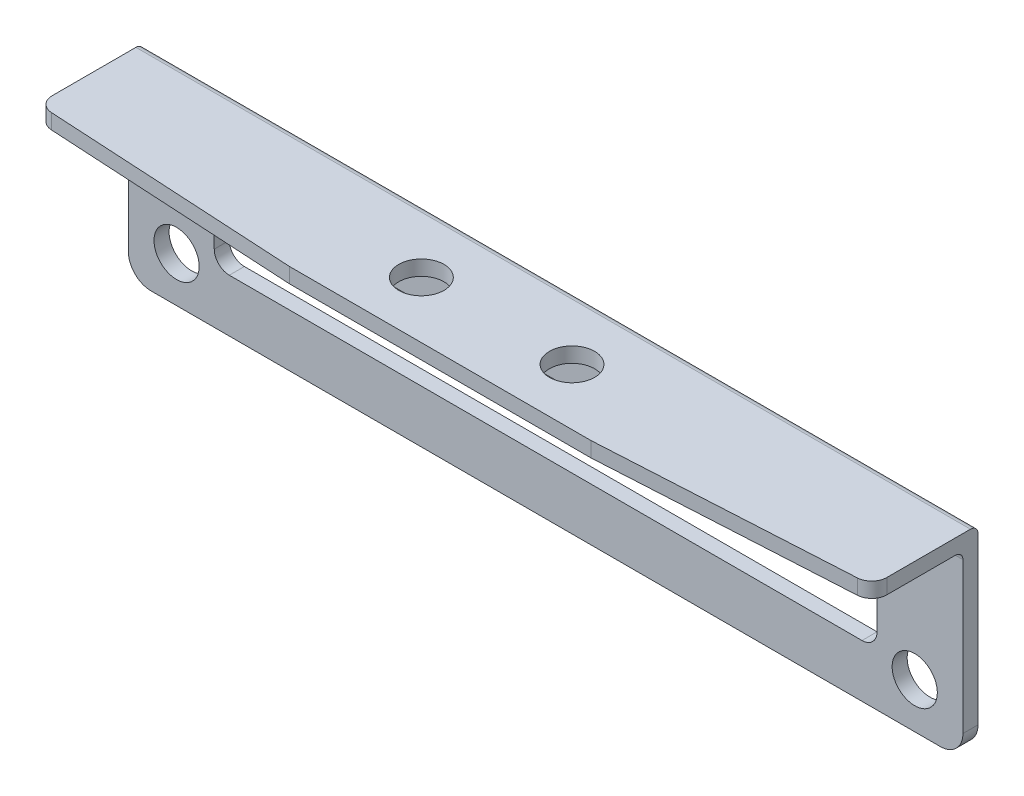
from build123d import *

# Parameters (mm, degrees)
SKETCH_1_W          = 55.4
SKETCH_1_H          = 13
SKETCH_1_R          = 1.5
SKETCH_1_W_2        = 44
SKETCH_1_H_2        = 4.8
EXTRUDE_1_DEPTH     = 1
SKETCH_2_W          = 55.4
SKETCH_2_H          = 1
EXTRUDE_2_DEPTH     = 7
CUT_EXTRUDE_1_DEPTH = 2
SKETCH_4_R          = 1.5
CUT_EXTRUDE_2_DEPTH = 2
FILLET_1_R          = 0.5
FILLET_2_R          = 1
FILLET_3_R          = 1.5
FILLET_4_R          = 1


with BuildPart() as part:
    # 草图1 → 凸台-拉伸1 (new body)
    with BuildSketch(Plane.XY):
        with Locations((0, 6.5)):
            Rectangle(SKETCH_1_W, SKETCH_1_H)
        with Locations((-24.5, 3)):
            Circle(SKETCH_1_R, mode=Mode.SUBTRACT)
        with Locations((24.5, 3)):
            Circle(SKETCH_1_R, mode=Mode.SUBTRACT)
        with Locations((0, 5.9)):
            Rectangle(SKETCH_1_W_2, SKETCH_1_H_2, mode=Mode.SUBTRACT)
    extrude(amount=EXTRUDE_1_DEPTH)

    # 草图2 → 凸台-拉伸2 (add)
    with BuildSketch(Plane.XY.offset(1)):
        with Locations((0, 12.5)):
            Rectangle(SKETCH_2_W, SKETCH_2_H)
    extrude(amount=EXTRUDE_2_DEPTH)

    # 草图3 → 切除-拉伸1 (cut, through all)
    with BuildSketch(Plane.XZ.offset(-12)):
        Polygon((-27.7, 8), (-27.7, 7), (-10, 8), align=None)
        Polygon((27.7, 8), (27.7, 7), (10, 8), align=None)
    extrude(amount=-CUT_EXTRUDE_1_DEPTH, mode=Mode.SUBTRACT)

    # 草图4 → 切除-拉伸2 (cut, through all)
    with BuildSketch(Plane.XZ.offset(-12)):
        with Locations((-5, 4.25)):
            Circle(SKETCH_4_R)
        with Locations((5, 4.25)):
            Circle(SKETCH_4_R)
    extrude(amount=-CUT_EXTRUDE_2_DEPTH, mode=Mode.SUBTRACT)

    # 圆角1
    fillet_1_edges = [part.edges().sort_by_distance(p)[0] for p in [
        (0, 13, 0),
        (0, 12, 1),
    ]]
    fillet(fillet_1_edges, radius=FILLET_1_R)

    # 圆角2
    fillet_2_edges = [part.edges().sort_by_distance(p)[0] for p in [
        (22, 3.5, 0.5),
        (22, 8.3, 0.5),
        (-22, 8.3, 0.5),
        (-22, 3.5, 0.5),
    ]]
    fillet(fillet_2_edges, radius=FILLET_2_R)

    # 圆角3
    fillet_3_edges = [part.edges().sort_by_distance(p)[0] for p in [
        (27.7, 0, 0.5),
        (-27.7, 0, 0.5),
    ]]
    fillet(fillet_3_edges, radius=FILLET_3_R)

    # 圆角4
    fillet_4_edges = [part.edges().sort_by_distance(p)[0] for p in [
        (-27.7, 12.5, 7),
        (27.7, 12.5, 7),
    ]]
    fillet(fillet_4_edges, radius=FILLET_4_R)


solid = part.part
